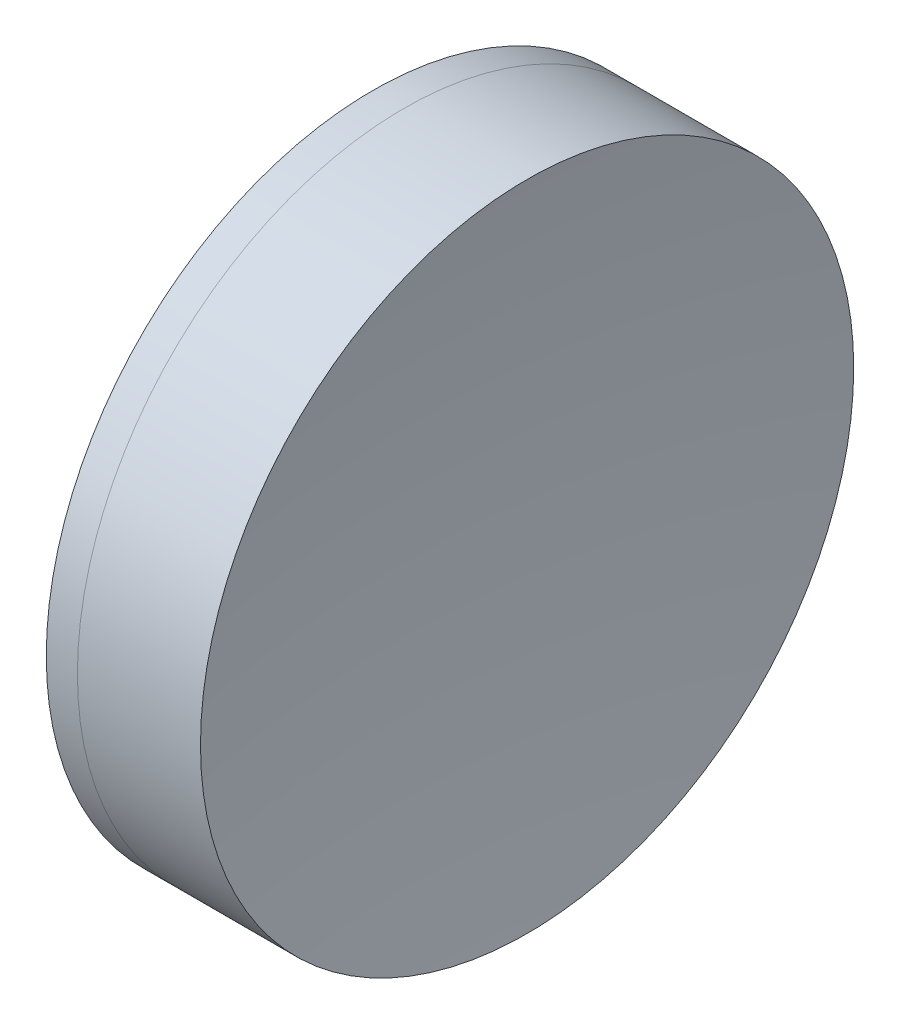
from build123d import *


with BuildPart() as part:
    # 草图1 one side → 旋转1 (revolve)
    with BuildSketch(Plane(origin=(0, 0, 0), x_dir=(1, 0, 0), z_dir=(0, 1, 0)), mode=Mode.PRIVATE) as revolve_1_sk:
        with BuildLine():
            ThreePointArc((57.779077555, 12.7), (56.375415363, 6.41882619), (55.904159254, 0))
            Line((55.904159254, 0), (60.404159254, 0))
            ThreePointArc((60.404159254, 0), (60.049188518, 6.389320768), (58.988645388, 12.7))
            Line((58.988645388, 12.7), (57.779077555, 12.7))
        make_face()
    revolve(revolve_1_sk.sketch.rotate(Axis((-0.816062176, 0, 0), (1, 0, 0)), 180), axis=Axis((-0.816062176, 0, 0), (1, 0, 0)))  # turned: the seam where the file's is


with BuildPart() as body_2:
    # 草图2 one side → 旋转2 (revolve)
    with BuildSketch(Plane(origin=(0, 0, 0), x_dir=(1, 0, 0), z_dir=(0, 1, 0)), mode=Mode.PRIVATE) as revolve_2_sk:
        with BuildLine():
            Line((63.774351687, 12.7), (58.988645388, 12.7))
            ThreePointArc((58.988645388, 12.7), (60.049188518, 6.389320768), (60.404159254, 0))
            Line((60.404159254, 0), (62.904159254, 0))
            ThreePointArc((62.904159254, 0), (63.121962104, 6.364888744), (63.774351687, 12.7))
        make_face()
    revolve(revolve_2_sk.sketch.rotate(Axis((-0.551919993, 0, 0), (1, 0, 0)), 180), axis=Axis((-0.551919993, 0, 0), (1, 0, 0)))  # turned: the seam where the file's is


solid = Compound([part.part, body_2.part])
